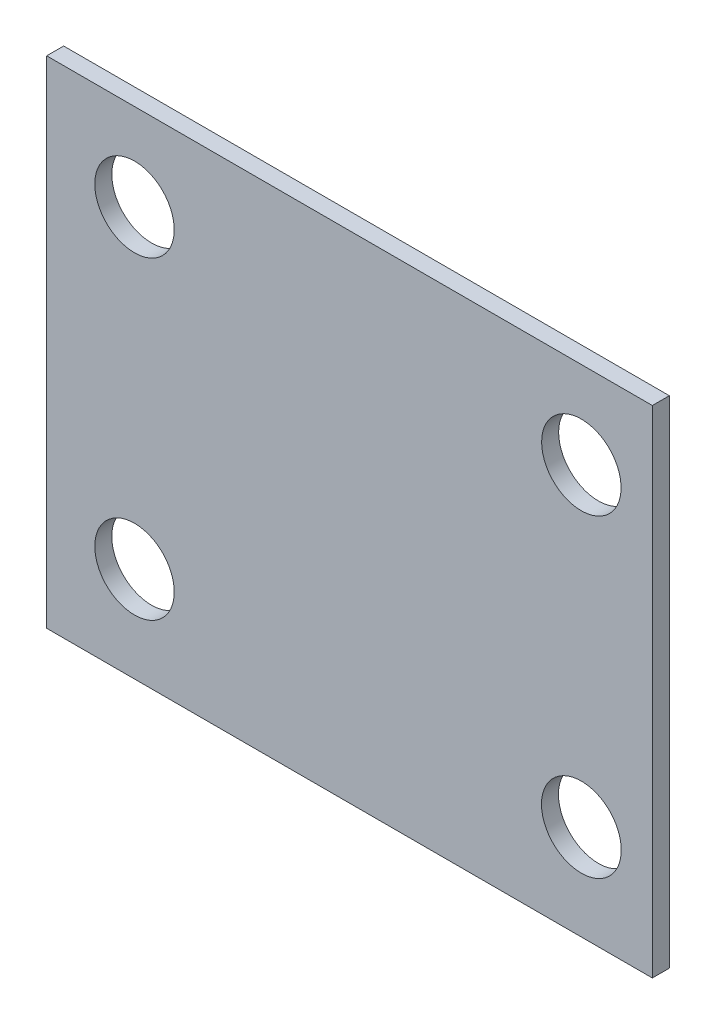
from build123d import *

# Parameters (mm, degrees)
SKETCH2_W           = 60.25
SKETCH2_H           = 49.32
BOSS_EXTRUDE1_DEPTH = 1.69
SKETCH3_R           = 3.952147655
SKETCH3_R_2         = 3.952150029
SKETCH3_R_3         = 3.968749046
SKETCH3_R_4         = 3.952152839
CUT_EXTRUDE1_DEPTH  = 2.69


with BuildPart() as part:
    # Sketch2 → Boss-Extrude1 (new body)
    with BuildSketch(Plane.XY):
        with Locations((30.125, 24.66)):
            Rectangle(SKETCH2_W, SKETCH2_H)
    extrude(amount=BOSS_EXTRUDE1_DEPTH)

    # Sketch3 → Cut-Extrude1 (cut, through all)
    with BuildSketch(Plane(origin=(0, 0, 0), x_dir=(-1, 0, 0), z_dir=(0, 0, -1))):
        with Locations((-8.738893953, 40.670430147)):
            Circle(SKETCH3_R)
        with Locations((-53.188901724, 40.670430147)):
            Circle(SKETCH3_R_2)
        with Locations((-53.188891655, 9.466519291)):
            Circle(SKETCH3_R_3)
        with Locations((-8.738896778, 9.466533547)):
            Circle(SKETCH3_R_4)
    extrude(amount=-CUT_EXTRUDE1_DEPTH, mode=Mode.SUBTRACT)


solid = part.part
